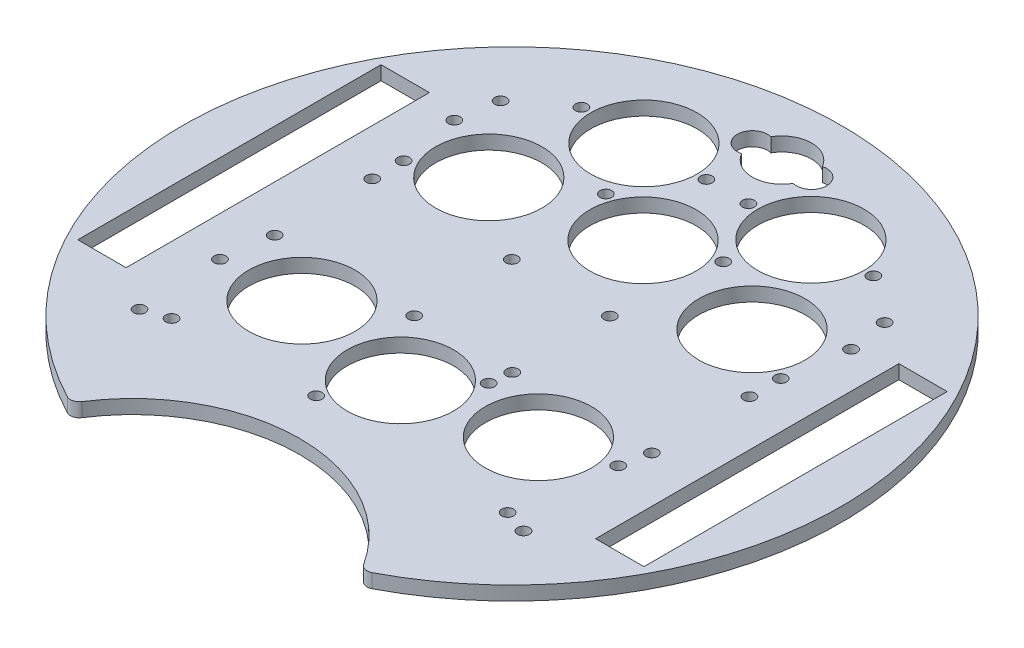
from build123d import *

# Parameters (mm, degrees)
SKETCH1_R           = 1.35
SKETCH1_R_2         = 12.095
SKETCH1_W           = 11
SKETCH1_H           = 69
BOSS_EXTRUDE2_DEPTH = 3.175
FILLET1_R           = 2


with BuildPart() as part:
    # Sketch1 → Boss-Extrude2 (new body)
    with BuildSketch(Plane(origin=(0, 0, 0), x_dir=(1, 0, 0), z_dir=(0, 1, 0))):
        with BuildLine():
            ThreePointArc((32.995567884, -67.352004425), (0, 75), (-32.995567884, -67.352004425))
            ThreePointArc((-32.995567884, -67.352004425), (0, -48.302004425), (32.995567884, -67.352004425))
        make_face()
        with Locations((-42.910067426, 11.1)):
            Circle(SKETCH1_R, mode=Mode.SUBTRACT)
        with Locations((-42.910067426, -11.1)):
            Circle(SKETCH1_R, mode=Mode.SUBTRACT)
        with Locations((-11.160067426, -11.1)):
            Circle(SKETCH1_R, mode=Mode.SUBTRACT)
        with Locations((-11.160067426, 11.1)):
            Circle(SKETCH1_R, mode=Mode.SUBTRACT)
        with Locations((11.160067426, 11.1)):
            Circle(SKETCH1_R, mode=Mode.SUBTRACT)
        with Locations((11.160067426, -11.1)):
            Circle(SKETCH1_R, mode=Mode.SUBTRACT)
        with Locations((42.910067426, -11.1)):
            Circle(SKETCH1_R, mode=Mode.SUBTRACT)
        with Locations((42.910067426, 11.1)):
            Circle(SKETCH1_R, mode=Mode.SUBTRACT)
        with Locations((26.905821676, -20.904643604)):
            Circle(SKETCH1_R_2, mode=Mode.SUBTRACT)
        with Locations((19, 49)):
            Circle(SKETCH1_R_2, mode=Mode.SUBTRACT)
        with Locations((0, 29.793589551)):
            Circle(SKETCH1_R_2, mode=Mode.SUBTRACT)
        with Locations((0, -25.409190322)):
            Circle(SKETCH1_R_2, mode=Mode.SUBTRACT)
        with Locations((29.939937248, 24.651901309)):
            Circle(SKETCH1_R_2, mode=Mode.SUBTRACT)
        with Locations((-26.905821676, -20.904643604)):
            Circle(SKETCH1_R_2, mode=Mode.SUBTRACT)
        with Locations((-29.939937248, 24.651901309)):
            Circle(SKETCH1_R_2, mode=Mode.SUBTRACT)
        with Locations((-33.21799214, 49)):
            Circle(SKETCH1_R, mode=Mode.SUBTRACT)
        with Locations((-4.78200786, 49)):
            Circle(SKETCH1_R, mode=Mode.SUBTRACT)
        with Locations((4.78200786, 49)):
            Circle(SKETCH1_R, mode=Mode.SUBTRACT)
        with Locations((-42.910067426, 18.234848025)):
            Circle(SKETCH1_R, mode=Mode.SUBTRACT)
        with Locations((42.910067426, 18.234848025)):
            Circle(SKETCH1_R, mode=Mode.SUBTRACT)
        with Locations((-19, 49)):
            Circle(SKETCH1_R_2, mode=Mode.SUBTRACT)
        with Locations((45.13872464, 31.997163897)):
            Circle(SKETCH1_R, mode=Mode.SUBTRACT)
        with Locations((-45.13872464, 31.997163897)):
            Circle(SKETCH1_R, mode=Mode.SUBTRACT)
        with Locations((13.346873881, 34.693819966)):
            Circle(SKETCH1_R, mode=Mode.SUBTRACT)
        with Locations((-6.55476095, -38.026099982)):
            Circle(SKETCH1_R, mode=Mode.SUBTRACT)
        with Locations((-13.346873881, 34.693819966)):
            Circle(SKETCH1_R, mode=Mode.SUBTRACT)
        with Locations((10.597026674, -15.930038136)):
            Circle(SKETCH1_R, mode=Mode.SUBTRACT)
        with Locations((-38.234289702, -39.23697625)):
            Circle(SKETCH1_R, mode=Mode.SUBTRACT)
        with Locations((-43.684644625, -41.077803557)):
            Circle(SKETCH1_R, mode=Mode.SUBTRACT)
        with Locations((-43.684644625, 41.077803557)):
            Circle(SKETCH1_R, mode=Mode.SUBTRACT)
        with Locations((43.684644625, -41.077803557)):
            Circle(SKETCH1_R, mode=Mode.SUBTRACT)
        with Locations((33.21799214, 49)):
            Circle(SKETCH1_R, mode=Mode.SUBTRACT)
        with Locations((43.684644625, 41.077803557)):
            Circle(SKETCH1_R, mode=Mode.SUBTRACT)
        with Locations((-44.385223141, -22.074211772)):
            Circle(SKETCH1_R, mode=Mode.SUBTRACT)
        with Locations((41.601681906, -17.457756634)):
            Circle(SKETCH1_R, mode=Mode.SUBTRACT)
        with Locations((38.234289702, -39.23697625)):
            Circle(SKETCH1_R, mode=Mode.SUBTRACT)
        with Locations((58.910067426, 0.102907352)):
            Rectangle(SKETCH1_W, SKETCH1_H, mode=Mode.SUBTRACT)
        with Locations((-58.910067426, 0.102907352)):
            Rectangle(SKETCH1_W, SKETCH1_H, mode=Mode.SUBTRACT)
        with BuildLine():
            ThreePointArc((-5.853899988, 64.744946271), (0.003726822, 68.153564176), (5.857575472, 64.738461857))
            ThreePointArc((5.857575472, 64.738461857), (10.16, 61.422565207), (5.857575472, 58.106668557))
            ThreePointArc((5.857575472, 58.106668557), (0.003726822, 54.691566239), (-5.853899988, 58.100184144))
            ThreePointArc((-5.853899988, 58.100184144), (-10.167207264, 61.422565207), (-5.853899988, 64.744946271))
        make_face(mode=Mode.SUBTRACT)
    extrude(amount=BOSS_EXTRUDE2_DEPTH)

    # Fillet1
    fillet1_edges = [part.edges().sort_by_distance(p)[0] for p in [
        (-32.995567884, 1.5875, 67.352004425),
        (32.995567884, 1.5875, 67.352004425),
    ]]
    fillet(fillet1_edges, radius=FILLET1_R)


solid = part.part
